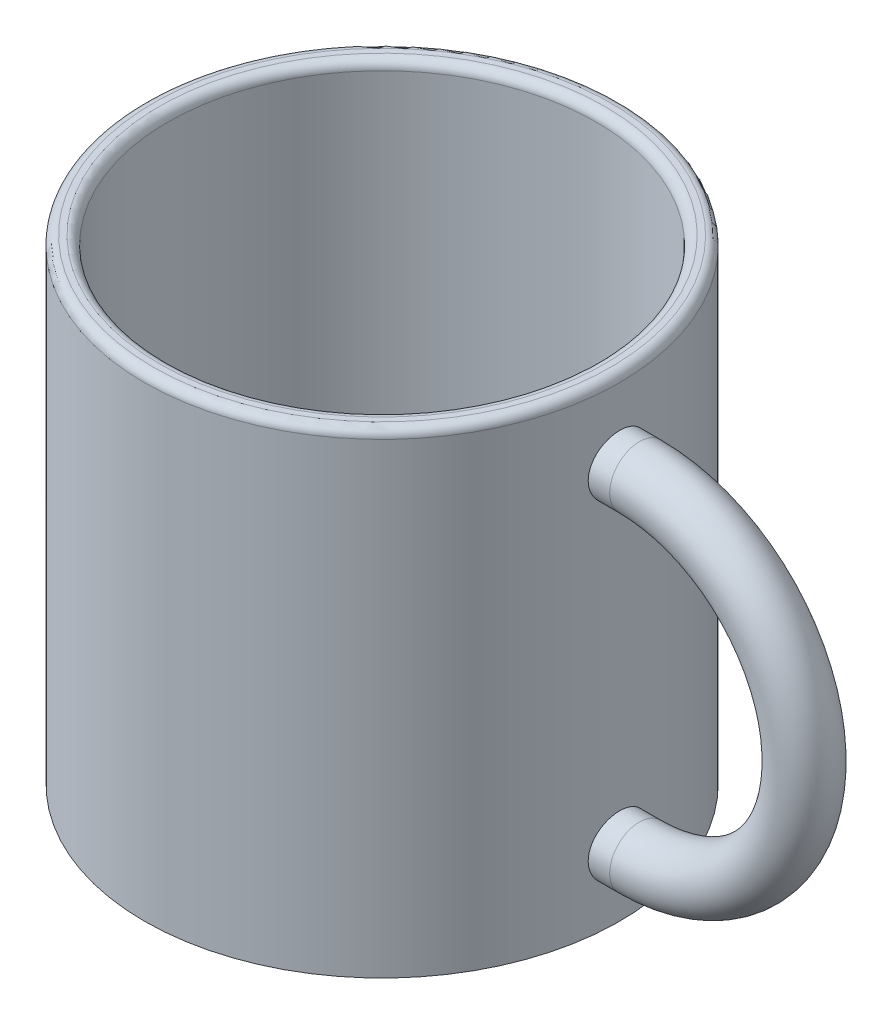
from build123d import *

# Parameters (mm, degrees)
SKETCH1_R          = 20
EXTRUDE1_DEPTH     = 40
SKETCH2_R          = 2.5
SKETCH4_R          = 18
CUT_EXTRUDE1_DEPTH = 38
FILLET1_R          = 0.75
FILLET2_R          = 0.75
SCALE2_SCALE       = 1.8


with BuildPart() as part:
    # Sketch1 → Extrude1 (new body)
    with BuildSketch(Plane(origin=(0, 0, 0), x_dir=(1, 0, 0), z_dir=(0, 1, 0))):
        Circle(SKETCH1_R)
    extrude(amount=EXTRUDE1_DEPTH)

    # Sweep1: sweep along a path in Sketch3
    with BuildLine(Plane.XY) as sweep1_path:
        Line((0, 30.773001508), (21.65, 30.773001508))
        ThreePointArc((21.65, 30.773001508), (33.01, 19.413001508), (21.65, 8.053001508))
        Line((21.65, 8.053001508), (0, 8.053001508))
    # Sketch2 → Sweep1 (sweep)
    with BuildSketch(Plane(origin=(0, 0, 0), x_dir=(0, 0, -1), z_dir=(1, 0, 0))):
        with Locations((0, 33.273001508)):
            Circle(SKETCH2_R)
    sweep(path=sweep1_path.line)

    # Sketch4 → Cut-Extrude1 (cut)
    with BuildSketch(Plane(origin=(0, 40, 0), x_dir=(-1, 0, 0), z_dir=(0, 1, 0))):
        Circle(SKETCH4_R)
    extrude(amount=-CUT_EXTRUDE1_DEPTH, mode=Mode.SUBTRACT)

    # Fillet1
    fillet1_edges = [part.edges().sort_by_distance(p)[0] for p in [
        (18, 40, 0),
        (-20, 40, 0),
    ]]
    fillet(fillet1_edges, radius=FILLET1_R)

    # Fillet2
    fillet2_edges = [part.edges().sort_by_distance(p)[0] for p in [
        (18, 2, 0),
    ]]
    fillet(fillet2_edges, radius=FILLET2_R)


with BuildPart() as part_1:
    # Scale2: scaled about (2.200885097, 16.795438051, 2.029e-06)
    add(part.part.scale(SCALE2_SCALE).moved(Location((-1.760708078, -13.436350441, -1.623e-06))))


solid = part_1.part
